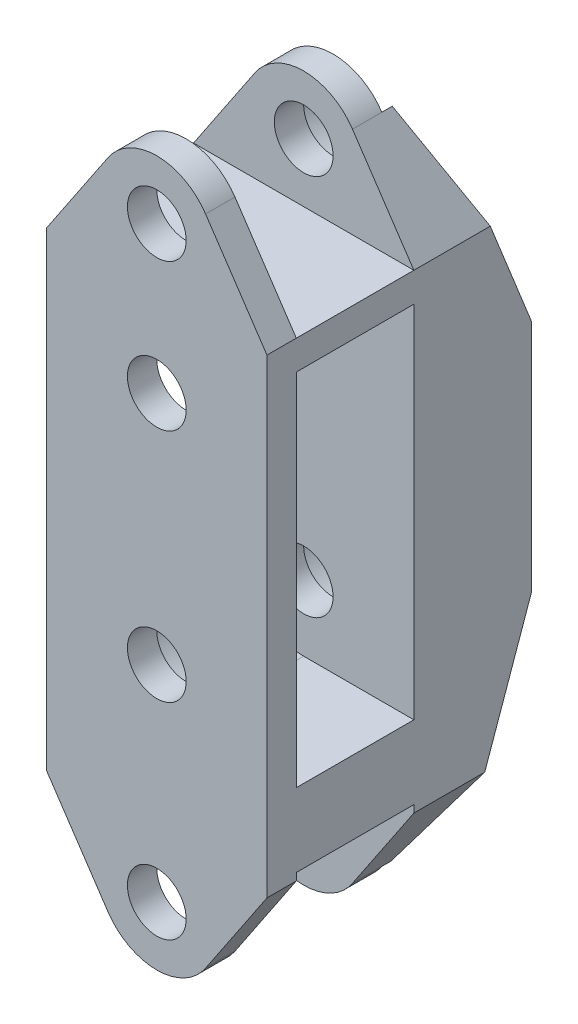
from build123d import *

# Parameters (mm, degrees)
SKETCH1_W               = 23.8125
SKETCH1_H               = 76.2
BOSS_EXTRUDE1_DEPTH     = 28.575
SKETCH2_R               = 3.175
CUT_EXTRUDE1_DEPTH      = 31.75
SKETCH11_W              = 12.7
SKETCH11_H              = 12.7
SKETCH11_H_2            = 60.325
CUT_EXTRUDE7_DEPTH      = 12.90625
CUT_EXTRUDE7_DEPTH_BACK = 12.90625
BOSS_EXTRUDE3_DEPTH     = 12.7
CUT_EXTRUDE8_START      = -3.175
SKETCH13_R              = 6.35
CUT_EXTRUDE8_DEPTH      = 10.525


with BuildPart() as part:
    # Sketch1 → Boss-Extrude1 (new body)
    with BuildSketch(Plane.XY):
        Rectangle(SKETCH1_W, SKETCH1_H)
    extrude(amount=BOSS_EXTRUDE1_DEPTH)

    # Sketch2 → Cut-Extrude1 (cut)
    with BuildSketch(Plane.XY.offset(28.575)):
        with BuildLine():
            Line((-11.90625, -38.1), (0, -38.1))
            ThreePointArc((0, -38.1), (-2.988235294, -37.352941176), (-5.273356401, -35.287543253))
            Line((-5.273356401, -35.287543253), (-11.90625, -25.4))
            Line((-11.90625, -25.4), (-11.90625, -38.1))
        make_face()
        with BuildLine():
            Line((11.90625, -38.1), (11.90625, -25.4))
            Line((11.90625, -25.4), (5.273356401, -35.287543253))
            ThreePointArc((5.273356401, -35.287543253), (2.988235294, -37.352941176), (0, -38.1))
            Line((0, -38.1), (11.90625, -38.1))
        make_face()
        with BuildLine():
            ThreePointArc((0, 38.1), (2.988235294, 37.352941176), (5.273356401, 35.287543253))
            Line((5.273356401, 35.287543253), (11.90625, 25.4))
            Line((11.90625, 25.4), (11.90625, 38.1))
            Line((11.90625, 38.1), (0, 38.1))
        make_face()
        with BuildLine():
            ThreePointArc((-5.273356401, 35.287543253), (-2.988235294, 37.352941176), (0, 38.1))
            Line((0, 38.1), (-11.90625, 38.1))
            Line((-11.90625, 38.1), (-11.90625, 25.4))
            Line((-11.90625, 25.4), (-5.273356401, 35.287543253))
        make_face()
        with Locations((0, 31.75)):
            Circle(SKETCH2_R)
        with Locations((0, 15.875)):
            Circle(SKETCH2_R)
        with Locations((0, -9.525)):
            Circle(SKETCH2_R)
        with Locations((0, -31.75)):
            Circle(SKETCH2_R)
    extrude(amount=-CUT_EXTRUDE1_DEPTH, mode=Mode.SUBTRACT)

    # Sketch11 → Cut-Extrude7 (cut, two sides)
    with BuildSketch(Plane(origin=(0, 0, 0), x_dir=(0, 0, -1), z_dir=(1, 0, 0))) as cut_extrude7_sk:
        with Locations((-19.05, 31.75)):
            Rectangle(SKETCH11_W, SKETCH11_H)
        with Locations((-19.05, -7.9375)):
            Rectangle(SKETCH11_W, SKETCH11_H_2)
        Polygon((0, 14.2875), (-9.525, 38.1), (0, 38.1), align=None)
        Polygon((0, -11.1125), (-9.525, -38.1), (0, -38.1), align=None)
    extrude(amount=CUT_EXTRUDE7_DEPTH, mode=Mode.SUBTRACT)
    extrude(cut_extrude7_sk.sketch, amount=-CUT_EXTRUDE7_DEPTH_BACK, mode=Mode.SUBTRACT)

    # Sketch12 → Boss-Extrude3 (add)
    with BuildSketch(Plane(origin=(0, 0, 25.4), x_dir=(-1, 0, 0), z_dir=(0, 0, -1))):
        with BuildLine():
            Line((0, -24.60625), (-11.90625, -24.60625))
            Line((-11.90625, -24.60625), (-11.90625, -16.66875))
            Line((-11.90625, -16.66875), (0, -16.66875))
            ThreePointArc((0, -16.66875), (5.051394068, -14.576394068), (7.14375, -9.525))
            Line((7.14375, -9.525), (11.90625, -9.525))
            Line((11.90625, -9.525), (11.90625, -25.4))
            Line((11.90625, -25.4), (7.096564462, -32.569717572))
            ThreePointArc((7.096564462, -32.569717572), (5.333339548, -26.997247815), (0, -24.60625))
        make_face()
    extrude(amount=BOSS_EXTRUDE3_DEPTH)

    # Sketch13 → Cut-Extrude8 (cut, through all)
    with BuildSketch(Plane.XY.offset(12.7).offset(CUT_EXTRUDE8_START)):
        with Locations((0, 31.75)):
            Circle(SKETCH13_R)
        with Locations((0, 15.875)):
            Circle(SKETCH13_R)
        with Locations((0, -9.525)):
            Circle(SKETCH13_R)
        with Locations((0, -31.75)):
            Circle(SKETCH13_R)
    extrude(amount=-CUT_EXTRUDE8_DEPTH, mode=Mode.SUBTRACT)


solid = part.part
